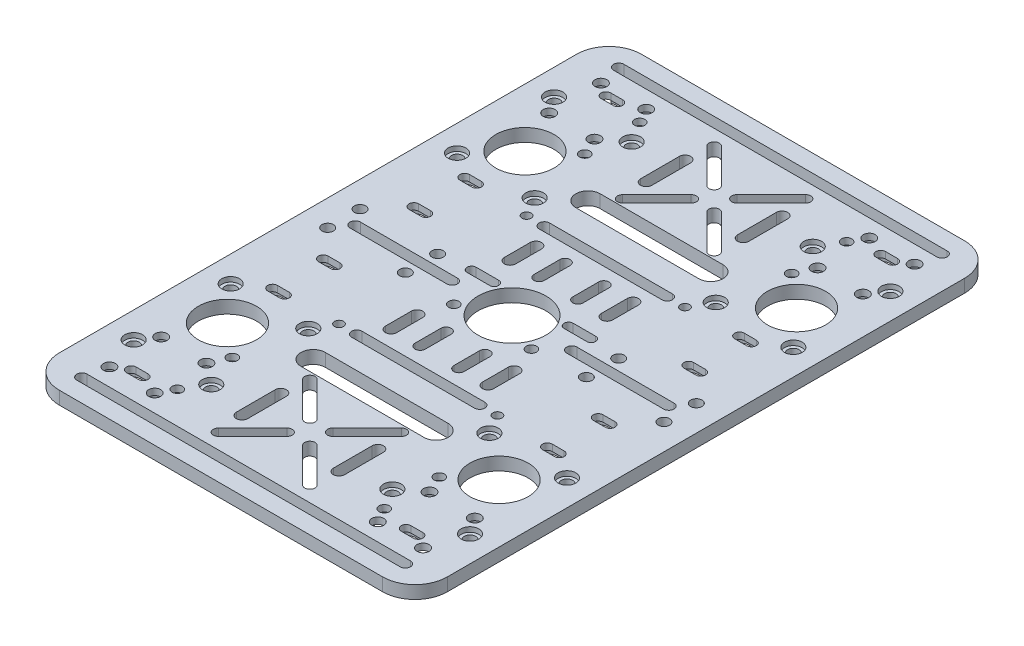
from build123d import *

# Parameters (mm, degrees)
SKETCH1_W           = 120
SKETCH1_H           = 180
SKETCH1_R           = 1.4
SKETCH1_R_2         = 10.5
SKETCH1_R_3         = 1.6
BOSS_EXTRUDE1_DEPTH = 4
SKETCH2_R           = 1.6
SKETCH2_R_2         = 1.75
SKETCH2_R_3         = 1.85
CUT_EXTRUDE1_DEPTH  = 5
FILLET1_R           = 10
SKETCH_1_R          = 2.75
CUT_EXTRUDE_1_DEPTH = 1.5
SKETCH_2_R          = 3
CUT_EXTRUDE_2_DEPTH = 2
SKETCH_3_R          = 9
CUT_EXTRUDE_3_DEPTH = 5


with BuildPart() as part:
    # Sketch1 → Boss-Extrude1 (new body)
    with BuildSketch(Plane(origin=(0, 0, 0), x_dir=(1, 0, 0), z_dir=(0, 1, 0))):
        Rectangle(SKETCH1_W, SKETCH1_H)
        with Locations((-24.5, 29)):
            Circle(SKETCH1_R, mode=Mode.SUBTRACT)
        with Locations((24.5, 29)):
            Circle(SKETCH1_R, mode=Mode.SUBTRACT)
        with Locations((-24.5, -29)):
            Circle(SKETCH1_R, mode=Mode.SUBTRACT)
        with Locations((24.5, -29)):
            Circle(SKETCH1_R, mode=Mode.SUBTRACT)
        Circle(SKETCH1_R_2, mode=Mode.SUBTRACT)
        with Locations((12, -6)):
            Circle(SKETCH1_R_3, mode=Mode.SUBTRACT)
        with Locations((-12, -6)):
            Circle(SKETCH1_R_3, mode=Mode.SUBTRACT)
        with BuildLine():
            Line((-16.75, 68.5), (-16.75, 56.5))
            ThreePointArc((-16.75, 56.5), (-15, 54.75), (-13.25, 56.5))
            Line((-13.25, 56.5), (-13.25, 68.5))
            ThreePointArc((-13.25, 68.5), (-15, 70.25), (-16.75, 68.5))
        make_face(mode=Mode.SUBTRACT)
        with BuildLine():
            Line((16.75, -68.5), (16.75, -56.5))
            ThreePointArc((16.75, -56.5), (15, -54.75), (13.25, -56.5))
            Line((13.25, -56.5), (13.25, -68.5))
            ThreePointArc((13.25, -68.5), (15, -70.25), (16.75, -68.5))
        make_face(mode=Mode.SUBTRACT)
        with BuildLine():
            Line((-16.75, -68.5), (-16.75, -56.5))
            ThreePointArc((-16.75, -56.5), (-15, -54.75), (-13.25, -56.5))
            Line((-13.25, -56.5), (-13.25, -68.5))
            ThreePointArc((-13.25, -68.5), (-15, -70.25), (-16.75, -68.5))
        make_face(mode=Mode.SUBTRACT)
        with BuildLine():
            Line((11.5, 7.4), (18.5, 7.4))
            ThreePointArc((18.5, 7.4), (19.9, 6), (18.5, 4.6))
            Line((18.5, 4.6), (11.5, 4.6))
            ThreePointArc((11.5, 4.6), (10.1, 6), (11.5, 7.4))
        make_face(mode=Mode.SUBTRACT)
        with BuildLine():
            Line((-11.5, 7.4), (-18.5, 7.4))
            ThreePointArc((-18.5, 7.4), (-19.9, 6), (-18.5, 4.6))
            Line((-18.5, 4.6), (-11.5, 4.6))
            ThreePointArc((-11.5, 4.6), (-10.1, 6), (-11.5, 7.4))
        make_face(mode=Mode.SUBTRACT)
        with BuildLine():
            Line((4.666904756, 60.095836944), (15.273506474, 49.489235226))
            ThreePointArc((15.273506474, 49.489235226), (15.273506474, 47.226493526), (13.010764774, 47.226493526))
            Line((13.010764774, 47.226493526), (2.404163056, 57.833095244))
            ThreePointArc((2.404163056, 57.833095244), (2.404163056, 60.095836944), (4.666904756, 60.095836944))
        make_face(mode=Mode.SUBTRACT)
        with BuildLine():
            Line((-2.404163056, 57.833095244), (-13.010764774, 47.226493526))
            ThreePointArc((-13.010764774, 47.226493526), (-15.273506474, 47.226493526), (-15.273506474, 49.489235226))
            Line((-15.273506474, 49.489235226), (-4.666904756, 60.095836944))
            ThreePointArc((-4.666904756, 60.095836944), (-2.404163056, 60.095836944), (-2.404163056, 57.833095244))
        make_face(mode=Mode.SUBTRACT)
        with BuildLine():
            Line((-4.666904756, 64.904163056), (-15.273506474, 75.510764774))
            ThreePointArc((-15.273506474, 75.510764774), (-15.273506474, 77.773506474), (-13.010764774, 77.773506474))
            Line((-13.010764774, 77.773506474), (-2.404163056, 67.166904756))
            ThreePointArc((-2.404163056, 67.166904756), (-2.404163056, 64.904163056), (-4.666904756, 64.904163056))
        make_face(mode=Mode.SUBTRACT)
        with BuildLine():
            Line((2.404163056, 67.166904756), (13.010764774, 77.773506474))
            ThreePointArc((13.010764774, 77.773506474), (15.273506474, 77.773506474), (15.273506474, 75.510764774))
            Line((15.273506474, 75.510764774), (4.666904756, 64.904163056))
            ThreePointArc((4.666904756, 64.904163056), (2.404163056, 64.904163056), (2.404163056, 67.166904756))
        make_face(mode=Mode.SUBTRACT)
        with BuildLine():
            Line((4.666904756, -60.095836944), (15.273506474, -49.489235226))
            ThreePointArc((15.273506474, -49.489235226), (15.273506474, -47.226493526), (13.010764774, -47.226493526))
            Line((13.010764774, -47.226493526), (2.404163056, -57.833095244))
            ThreePointArc((2.404163056, -57.833095244), (2.404163056, -60.095836944), (4.666904756, -60.095836944))
        make_face(mode=Mode.SUBTRACT)
        with BuildLine():
            Line((-2.404163056, -57.833095244), (-13.010764774, -47.226493526))
            ThreePointArc((-13.010764774, -47.226493526), (-15.273506474, -47.226493526), (-15.273506474, -49.489235226))
            Line((-15.273506474, -49.489235226), (-4.666904756, -60.095836944))
            ThreePointArc((-4.666904756, -60.095836944), (-2.404163056, -60.095836944), (-2.404163056, -57.833095244))
        make_face(mode=Mode.SUBTRACT)
        with BuildLine():
            Line((-4.666904756, -64.904163056), (-15.273506474, -75.510764774))
            ThreePointArc((-15.273506474, -75.510764774), (-15.273506474, -77.773506474), (-13.010764774, -77.773506474))
            Line((-13.010764774, -77.773506474), (-2.404163056, -67.166904756))
            ThreePointArc((-2.404163056, -67.166904756), (-2.404163056, -64.904163056), (-4.666904756, -64.904163056))
        make_face(mode=Mode.SUBTRACT)
        with BuildLine():
            Line((2.404163056, -67.166904756), (13.010764774, -77.773506474))
            ThreePointArc((13.010764774, -77.773506474), (15.273506474, -77.773506474), (15.273506474, -75.510764774))
            Line((15.273506474, -75.510764774), (4.666904756, -64.904163056))
            ThreePointArc((4.666904756, -64.904163056), (2.404163056, -64.904163056), (2.404163056, -67.166904756))
        make_face(mode=Mode.SUBTRACT)
        with BuildLine():
            Line((-19, -38.75), (19, -38.75))
            ThreePointArc((19, -38.75), (22.75, -42.5), (19, -46.25))
            Line((19, -46.25), (-19, -46.25))
            ThreePointArc((-19, -46.25), (-22.75, -42.5), (-19, -38.75))
        make_face(mode=Mode.SUBTRACT)
        with BuildLine():
            Line((-19, 38.75), (19, 38.75))
            ThreePointArc((19, 38.75), (22.75, 42.5), (19, 46.25))
            Line((19, 46.25), (-19, 46.25))
            ThreePointArc((-19, 46.25), (-22.75, 42.5), (-19, 38.75))
        make_face(mode=Mode.SUBTRACT)
        with BuildLine():
            Line((-48.5, 1.6), (-18.5, 1.6))
            ThreePointArc((-18.5, 1.6), (-16.9, 0), (-18.5, -1.6))
            Line((-18.5, -1.6), (-48.5, -1.6))
            ThreePointArc((-48.5, -1.6), (-50.1, 0), (-48.5, 1.6))
        make_face(mode=Mode.SUBTRACT)
        with BuildLine():
            Line((-50, -81.4), (50, -81.4))
            ThreePointArc((50, -81.4), (51.6, -83), (50, -84.6))
            Line((50, -84.6), (-50, -84.6))
            ThreePointArc((-50, -84.6), (-51.6, -83), (-50, -81.4))
        make_face(mode=Mode.SUBTRACT)
        with BuildLine():
            Line((48.5, 1.6), (18.5, 1.6))
            ThreePointArc((18.5, 1.6), (16.9, 0), (18.5, -1.6))
            Line((18.5, -1.6), (48.5, -1.6))
            ThreePointArc((48.5, -1.6), (50.1, 0), (48.5, 1.6))
        make_face(mode=Mode.SUBTRACT)
        with BuildLine():
            Line((-50, 81.4), (50, 81.4))
            ThreePointArc((50, 81.4), (51.6, 83), (50, 84.6))
            Line((50, 84.6), (-50, 84.6))
            ThreePointArc((-50, 84.6), (-51.6, 83), (-50, 81.4))
        make_face(mode=Mode.SUBTRACT)
        with BuildLine():
            Line((16.75, 68.5), (16.75, 56.5))
            ThreePointArc((16.75, 56.5), (15, 54.75), (13.25, 56.5))
            Line((13.25, 56.5), (13.25, 68.5))
            ThreePointArc((13.25, 68.5), (15, 70.25), (16.75, 68.5))
        make_face(mode=Mode.SUBTRACT)
        with BuildLine():
            Line((-19, 30.6), (19, 30.6))
            ThreePointArc((19, 30.6), (20.6, 29), (19, 27.4))
            Line((19, 27.4), (-19, 27.4))
            ThreePointArc((-19, 27.4), (-20.6, 29), (-19, 30.6))
        make_face(mode=Mode.SUBTRACT)
        with BuildLine():
            Line((-4.4, 22.4), (-4.4, 14.4))
            ThreePointArc((-4.4, 14.4), (-6, 12.8), (-7.6, 14.4))
            Line((-7.6, 14.4), (-7.6, 22.4))
            ThreePointArc((-7.6, 22.4), (-6, 24), (-4.4, 22.4))
        make_face(mode=Mode.SUBTRACT)
        with BuildLine():
            Line((-13.25, 22.4), (-13.25, 14.4))
            ThreePointArc((-13.25, 14.4), (-15, 12.65), (-16.75, 14.4))
            Line((-16.75, 14.4), (-16.75, 22.4))
            ThreePointArc((-16.75, 22.4), (-15, 24.15), (-13.25, 22.4))
        make_face(mode=Mode.SUBTRACT)
        with BuildLine():
            Line((13.25, 22.4), (13.25, 14.4))
            ThreePointArc((13.25, 14.4), (15, 12.65), (16.75, 14.4))
            Line((16.75, 14.4), (16.75, 22.4))
            ThreePointArc((16.75, 22.4), (15, 24.15), (13.25, 22.4))
        make_face(mode=Mode.SUBTRACT)
        with BuildLine():
            Line((4.4, 22.4), (4.4, 14.4))
            ThreePointArc((4.4, 14.4), (6, 12.8), (7.6, 14.4))
            Line((7.6, 14.4), (7.6, 22.4))
            ThreePointArc((7.6, 22.4), (6, 24), (4.4, 22.4))
        make_face(mode=Mode.SUBTRACT)
        with BuildLine():
            Line((13.25, -22.4), (13.25, -14.4))
            ThreePointArc((13.25, -14.4), (15, -12.65), (16.75, -14.4))
            Line((16.75, -14.4), (16.75, -22.4))
            ThreePointArc((16.75, -22.4), (15, -24.15), (13.25, -22.4))
        make_face(mode=Mode.SUBTRACT)
        with BuildLine():
            Line((4.4, -22.4), (4.4, -14.4))
            ThreePointArc((4.4, -14.4), (6, -12.8), (7.6, -14.4))
            Line((7.6, -14.4), (7.6, -22.4))
            ThreePointArc((7.6, -22.4), (6, -24), (4.4, -22.4))
        make_face(mode=Mode.SUBTRACT)
        with BuildLine():
            Line((-4.4, -22.4), (-4.4, -14.4))
            ThreePointArc((-4.4, -14.4), (-6, -12.8), (-7.6, -14.4))
            Line((-7.6, -14.4), (-7.6, -22.4))
            ThreePointArc((-7.6, -22.4), (-6, -24), (-4.4, -22.4))
        make_face(mode=Mode.SUBTRACT)
        with BuildLine():
            Line((-13.25, -22.4), (-13.25, -14.4))
            ThreePointArc((-13.25, -14.4), (-15, -12.65), (-16.75, -14.4))
            Line((-16.75, -14.4), (-16.75, -22.4))
            ThreePointArc((-16.75, -22.4), (-15, -24.15), (-13.25, -22.4))
        make_face(mode=Mode.SUBTRACT)
        with BuildLine():
            Line((-19, -30.6), (19, -30.6))
            ThreePointArc((19, -30.6), (20.6, -29), (19, -27.4))
            Line((19, -27.4), (-19, -27.4))
            ThreePointArc((-19, -27.4), (-20.6, -29), (-19, -30.6))
        make_face(mode=Mode.SUBTRACT)
        with BuildLine():
            Line((40.65, -28.2), (44.35, -28.2))
            ThreePointArc((44.35, -28.2), (45.85, -29.7), (44.35, -31.2))
            Line((44.35, -31.2), (40.65, -31.2))
            ThreePointArc((40.65, -31.2), (39.15, -29.7), (40.65, -28.2))
        make_face(mode=Mode.SUBTRACT)
        with BuildLine():
            Line((40.65, 28.2), (44.35, 28.2))
            ThreePointArc((44.35, 28.2), (45.85, 29.7), (44.35, 31.2))
            Line((44.35, 31.2), (40.65, 31.2))
            ThreePointArc((40.65, 31.2), (39.15, 29.7), (40.65, 28.2))
        make_face(mode=Mode.SUBTRACT)
        with BuildLine():
            Line((-40.65, -28.2), (-44.35, -28.2))
            ThreePointArc((-44.35, -28.2), (-45.85, -29.7), (-44.35, -31.2))
            Line((-44.35, -31.2), (-40.65, -31.2))
            ThreePointArc((-40.65, -31.2), (-39.15, -29.7), (-40.65, -28.2))
        make_face(mode=Mode.SUBTRACT)
        with BuildLine():
            Line((-40.65, 28.2), (-44.35, 28.2))
            ThreePointArc((-44.35, 28.2), (-45.85, 29.7), (-44.35, 31.2))
            Line((-44.35, 31.2), (-40.65, 31.2))
            ThreePointArc((-40.65, 31.2), (-39.15, 29.7), (-40.65, 28.2))
        make_face(mode=Mode.SUBTRACT)
        with BuildLine():
            Line((44.35, -15.5), (40.65, -15.5))
            ThreePointArc((40.65, -15.5), (39.15, -14), (40.65, -12.5))
            Line((40.65, -12.5), (44.35, -12.5))
            ThreePointArc((44.35, -12.5), (45.85, -14), (44.35, -15.5))
        make_face(mode=Mode.SUBTRACT)
        with BuildLine():
            Line((-44.35, -15.5), (-40.65, -15.5))
            ThreePointArc((-40.65, -15.5), (-39.15, -14), (-40.65, -12.5))
            Line((-40.65, -12.5), (-44.35, -12.5))
            ThreePointArc((-44.35, -12.5), (-45.85, -14), (-44.35, -15.5))
        make_face(mode=Mode.SUBTRACT)
        with BuildLine():
            Line((-44.35, -71.9), (-40.65, -71.9))
            ThreePointArc((-40.65, -71.9), (-39.15, -73.4), (-40.65, -74.9))
            Line((-40.65, -74.9), (-44.35, -74.9))
            ThreePointArc((-44.35, -74.9), (-45.85, -73.4), (-44.35, -71.9))
        make_face(mode=Mode.SUBTRACT)
        with BuildLine():
            Line((44.35, -71.9), (40.65, -71.9))
            ThreePointArc((40.65, -71.9), (39.15, -73.4), (40.65, -74.9))
            Line((40.65, -74.9), (44.35, -74.9))
            ThreePointArc((44.35, -74.9), (45.85, -73.4), (44.35, -71.9))
        make_face(mode=Mode.SUBTRACT)
        with BuildLine():
            Line((44.35, 71.9), (40.65, 71.9))
            ThreePointArc((40.65, 71.9), (39.15, 73.4), (40.65, 74.9))
            Line((40.65, 74.9), (44.35, 74.9))
            ThreePointArc((44.35, 74.9), (45.85, 73.4), (44.35, 71.9))
        make_face(mode=Mode.SUBTRACT)
        with BuildLine():
            Line((-44.35, 71.9), (-40.65, 71.9))
            ThreePointArc((-40.65, 71.9), (-39.15, 73.4), (-40.65, 74.9))
            Line((-40.65, 74.9), (-44.35, 74.9))
            ThreePointArc((-44.35, 74.9), (-45.85, 73.4), (-44.35, 71.9))
        make_face(mode=Mode.SUBTRACT)
        with BuildLine():
            Line((44.35, 15.5), (40.65, 15.5))
            ThreePointArc((40.65, 15.5), (39.15, 14), (40.65, 12.5))
            Line((40.65, 12.5), (44.35, 12.5))
            ThreePointArc((44.35, 12.5), (45.85, 14), (44.35, 15.5))
        make_face(mode=Mode.SUBTRACT)
        with BuildLine():
            Line((-44.35, 15.5), (-40.65, 15.5))
            ThreePointArc((-40.65, 15.5), (-39.15, 14), (-40.65, 12.5))
            Line((-40.65, 12.5), (-44.35, 12.5))
            ThreePointArc((-44.35, 12.5), (-45.85, 14), (-44.35, 15.5))
        make_face(mode=Mode.SUBTRACT)
    extrude(amount=BOSS_EXTRUDE1_DEPTH)

    # Sketch2 → Cut-Extrude1 (cut, through all)
    with BuildSketch(Plane(origin=(0, 4, 0), x_dir=(1, 0, 0), z_dir=(0, 1, 0))):
        with Locations((32, -71.5)):
            Circle(SKETCH2_R)
        with Locations((32, -54.5)):
            Circle(SKETCH2_R)
        with Locations((-32, -71.5)):
            Circle(SKETCH2_R)
        with Locations((-32, -54.5)):
            Circle(SKETCH2_R)
        with Locations((32, 71.5)):
            Circle(SKETCH2_R)
        with Locations((32, 54.5)):
            Circle(SKETCH2_R)
        with Locations((-32, 71.5)):
            Circle(SKETCH2_R)
        with Locations((-32, 54.5)):
            Circle(SKETCH2_R)
        with Locations((52, 35)):
            Circle(SKETCH2_R_2)
        with Locations((28, 35)):
            Circle(SKETCH2_R_2)
        with Locations((28, 65)):
            Circle(SKETCH2_R_2)
        with Locations((52, 65)):
            Circle(SKETCH2_R_2)
        with Locations((-52, 65)):
            Circle(SKETCH2_R_2)
        with Locations((-28, 65)):
            Circle(SKETCH2_R_2)
        with Locations((-28, 35)):
            Circle(SKETCH2_R_2)
        with Locations((-52, 35)):
            Circle(SKETCH2_R_2)
        with Locations((-28, -65)):
            Circle(SKETCH2_R_2)
        with Locations((-52, -65)):
            Circle(SKETCH2_R_2)
        with Locations((-52, -35)):
            Circle(SKETCH2_R_2)
        with Locations((-28, -35)):
            Circle(SKETCH2_R_2)
        with Locations((52, -35)):
            Circle(SKETCH2_R_2)
        with Locations((52, -65)):
            Circle(SKETCH2_R_2)
        with Locations((28, -65)):
            Circle(SKETCH2_R_2)
        with Locations((28, -35)):
            Circle(SKETCH2_R_2)
        with Locations((28, 5)):
            Circle(SKETCH2_R_2)
        with Locations((52, 5)):
            Circle(SKETCH2_R_2)
        with Locations((28, -5)):
            Circle(SKETCH2_R_2)
        with Locations((52, -5)):
            Circle(SKETCH2_R_2)
        with Locations((-52, 5)):
            Circle(SKETCH2_R_2)
        with Locations((-28, 5)):
            Circle(SKETCH2_R_2)
        with Locations((-28, -5)):
            Circle(SKETCH2_R_2)
        with Locations((-52, -5)):
            Circle(SKETCH2_R_2)
        with Locations((-34.5, 76)):
            Circle(SKETCH2_R_3)
        with Locations((-48.5, 76)):
            Circle(SKETCH2_R_3)
        with Locations((-48.5, 60)):
            Circle(SKETCH2_R_3)
        with Locations((-34.5, 60)):
            Circle(SKETCH2_R_3)
        with Locations((34.5, 76)):
            Circle(SKETCH2_R_3)
        with Locations((48.5, 76)):
            Circle(SKETCH2_R_3)
        with Locations((48.5, 60)):
            Circle(SKETCH2_R_3)
        with Locations((34.5, 60)):
            Circle(SKETCH2_R_3)
        with Locations((-34.5, -76)):
            Circle(SKETCH2_R_3)
        with Locations((-48.5, -76)):
            Circle(SKETCH2_R_3)
        with Locations((-48.5, -60)):
            Circle(SKETCH2_R_3)
        with Locations((-34.5, -60)):
            Circle(SKETCH2_R_3)
        with Locations((34.5, -76)):
            Circle(SKETCH2_R_3)
        with Locations((34.5, -60)):
            Circle(SKETCH2_R_3)
        with Locations((48.5, -60)):
            Circle(SKETCH2_R_3)
        with Locations((48.5, -76)):
            Circle(SKETCH2_R_3)
    extrude(amount=-CUT_EXTRUDE1_DEPTH, mode=Mode.SUBTRACT)

    # Fillet1
    fillet1_edges = [part.edges().sort_by_distance(p)[0] for p in [
        (60, 2, 90),
        (-60, 2, 90),
        (-60, 2, -90),
        (60, 2, -90),
    ]]
    fillet(fillet1_edges, radius=FILLET1_R)

    # 草图1 → 切除-拉伸1 (cut)
    with BuildSketch(Plane(origin=(0, 4, 0), x_dir=(1, 0, 0), z_dir=(0, 1, 0))):
        with Locations((-28, 65)):
            Circle(SKETCH_1_R)
        with Locations((-52, 65)):
            Circle(SKETCH_1_R)
        with Locations((52, 65)):
            Circle(SKETCH_1_R)
        with Locations((28, 65)):
            Circle(SKETCH_1_R)
        with Locations((-52, -65)):
            Circle(SKETCH_1_R)
        with Locations((-28, -65)):
            Circle(SKETCH_1_R)
        with Locations((28, -65)):
            Circle(SKETCH_1_R)
        with Locations((52, -65)):
            Circle(SKETCH_1_R)
        with Locations((52, 35)):
            Circle(SKETCH_1_R)
        with Locations((28, 35)):
            Circle(SKETCH_1_R)
        with Locations((-28, 35)):
            Circle(SKETCH_1_R)
        with Locations((-52, 35)):
            Circle(SKETCH_1_R)
        with Locations((52, -35)):
            Circle(SKETCH_1_R)
        with Locations((28, -35)):
            Circle(SKETCH_1_R)
        with Locations((-52, -35)):
            Circle(SKETCH_1_R)
        with Locations((-28, -35)):
            Circle(SKETCH_1_R)
    extrude(amount=-CUT_EXTRUDE_1_DEPTH, mode=Mode.SUBTRACT)

    # 草图2 → 切除-拉伸2 (cut)
    with BuildSketch(Plane.XZ):
        with Locations((34.5, -60)):
            Circle(SKETCH_2_R)
        with Locations((-48.5, 60)):
            Circle(SKETCH_2_R)
        with Locations((-48.5, 76)):
            Circle(SKETCH_2_R)
        with BuildLine():
            ThreePointArc((-40.65, 76.4), (-37.65, 73.4), (-40.65, 70.4))
            Line((-40.65, 70.4), (-44.35, 70.4))
            ThreePointArc((-44.35, 70.4), (-47.35, 73.4), (-44.35, 76.4))
            Line((-44.35, 76.4), (-40.65, 76.4))
        make_face()
        with Locations((-34.5, 76)):
            Circle(SKETCH_2_R)
        with Locations((-34.5, 60)):
            Circle(SKETCH_2_R)
        with Locations((34.5, 76)):
            Circle(SKETCH_2_R)
        with Locations((34.5, 60)):
            Circle(SKETCH_2_R)
        with Locations((48.5, 60)):
            Circle(SKETCH_2_R)
        with Locations((48.5, 76)):
            Circle(SKETCH_2_R)
        with BuildLine():
            Line((44.35, 76.4), (40.65, 76.4))
            ThreePointArc((40.65, 76.4), (37.65, 73.4), (40.65, 70.4))
            Line((40.65, 70.4), (44.35, 70.4))
            ThreePointArc((44.35, 70.4), (47.35, 73.4), (44.35, 76.4))
        make_face()
        with BuildLine():
            ThreePointArc((40.65, 32.7), (37.65, 29.7), (40.65, 26.7))
            Line((40.65, 26.7), (44.35, 26.7))
            ThreePointArc((44.35, 26.7), (47.35, 29.7), (44.35, 32.7))
            Line((44.35, 32.7), (40.65, 32.7))
        make_face()
        with BuildLine():
            ThreePointArc((40.65, 17), (37.65, 14), (40.65, 11))
            Line((40.65, 11), (44.35, 11))
            ThreePointArc((44.35, 11), (47.35, 14), (44.35, 17))
            Line((44.35, 17), (40.65, 17))
        make_face()
        with BuildLine():
            Line((-44.35, 17), (-40.65, 17))
            ThreePointArc((-40.65, 17), (-37.65, 14), (-40.65, 11))
            Line((-40.65, 11), (-44.35, 11))
            ThreePointArc((-44.35, 11), (-47.35, 14), (-44.35, 17))
        make_face()
        with BuildLine():
            ThreePointArc((-40.65, 32.7), (-37.65, 29.7), (-40.65, 26.7))
            Line((-40.65, 26.7), (-44.35, 26.7))
            ThreePointArc((-44.35, 26.7), (-47.35, 29.7), (-44.35, 32.7))
            Line((-44.35, 32.7), (-40.65, 32.7))
        make_face()
        with BuildLine():
            ThreePointArc((-40.65, -17), (-37.65, -14), (-40.65, -11))
            Line((-40.65, -11), (-44.35, -11))
            ThreePointArc((-44.35, -11), (-47.35, -14), (-44.35, -17))
            Line((-44.35, -17), (-40.65, -17))
        make_face()
        with BuildLine():
            ThreePointArc((-40.65, -32.7), (-37.65, -29.7), (-40.65, -26.7))
            Line((-40.65, -26.7), (-44.35, -26.7))
            ThreePointArc((-44.35, -26.7), (-47.35, -29.7), (-44.35, -32.7))
            Line((-44.35, -32.7), (-40.65, -32.7))
        make_face()
        with BuildLine():
            ThreePointArc((44.35, -11), (47.35, -14), (44.35, -17))
            Line((44.35, -17), (40.65, -17))
            ThreePointArc((40.65, -17), (37.65, -14), (40.65, -11))
            Line((40.65, -11), (44.35, -11))
        make_face()
        with BuildLine():
            ThreePointArc((44.35, -26.7), (47.35, -29.7), (44.35, -32.7))
            Line((44.35, -32.7), (40.65, -32.7))
            ThreePointArc((40.65, -32.7), (37.65, -29.7), (40.65, -26.7))
            Line((40.65, -26.7), (44.35, -26.7))
        make_face()
        with Locations((48.5, -60)):
            Circle(SKETCH_2_R)
        with Locations((48.5, -76)):
            Circle(SKETCH_2_R)
        with BuildLine():
            ThreePointArc((40.65, -76.4), (37.65, -73.4), (40.65, -70.4))
            Line((40.65, -70.4), (44.35, -70.4))
            ThreePointArc((44.35, -70.4), (47.35, -73.4), (44.35, -76.4))
            Line((44.35, -76.4), (40.65, -76.4))
        make_face()
        with Locations((34.5, -76)):
            Circle(SKETCH_2_R)
        with Locations((-34.5, -76)):
            Circle(SKETCH_2_R)
        with Locations((-48.5, -76)):
            Circle(SKETCH_2_R)
        with BuildLine():
            Line((-44.35, -76.4), (-40.65, -76.4))
            ThreePointArc((-40.65, -76.4), (-37.65, -73.4), (-40.65, -70.4))
            Line((-40.65, -70.4), (-44.35, -70.4))
            ThreePointArc((-44.35, -70.4), (-47.35, -73.4), (-44.35, -76.4))
        make_face()
        with Locations((-48.5, -60)):
            Circle(SKETCH_2_R)
        with Locations((-34.5, -60)):
            Circle(SKETCH_2_R)
        with Locations((-32, 71.5)):
            Circle(SKETCH_2_R)
        with Locations((-32, 54.5)):
            Circle(SKETCH_2_R)
        with Locations((32, 54.5)):
            Circle(SKETCH_2_R)
        with Locations((32, 71.5)):
            Circle(SKETCH_2_R)
        with Locations((-32, -54.5)):
            Circle(SKETCH_2_R)
        with Locations((-32, -71.5)):
            Circle(SKETCH_2_R)
        with Locations((32, -54.5)):
            Circle(SKETCH_2_R)
        with Locations((32, -71.5)):
            Circle(SKETCH_2_R)
    extrude(amount=-CUT_EXTRUDE_2_DEPTH, mode=Mode.SUBTRACT)

    # 草图3 → 切除-拉伸3 (cut, through all)
    with BuildSketch(Plane(origin=(0, 4, 0), x_dir=(1, 0, 0), z_dir=(0, 1, 0))):
        with Locations((42, -46)):
            Circle(SKETCH_3_R)
        with Locations((-42, -46)):
            Circle(SKETCH_3_R)
        with Locations((-42, 46)):
            Circle(SKETCH_3_R)
        with Locations((42, 46)):
            Circle(SKETCH_3_R)
    extrude(amount=-CUT_EXTRUDE_3_DEPTH, mode=Mode.SUBTRACT)


solid = part.part
